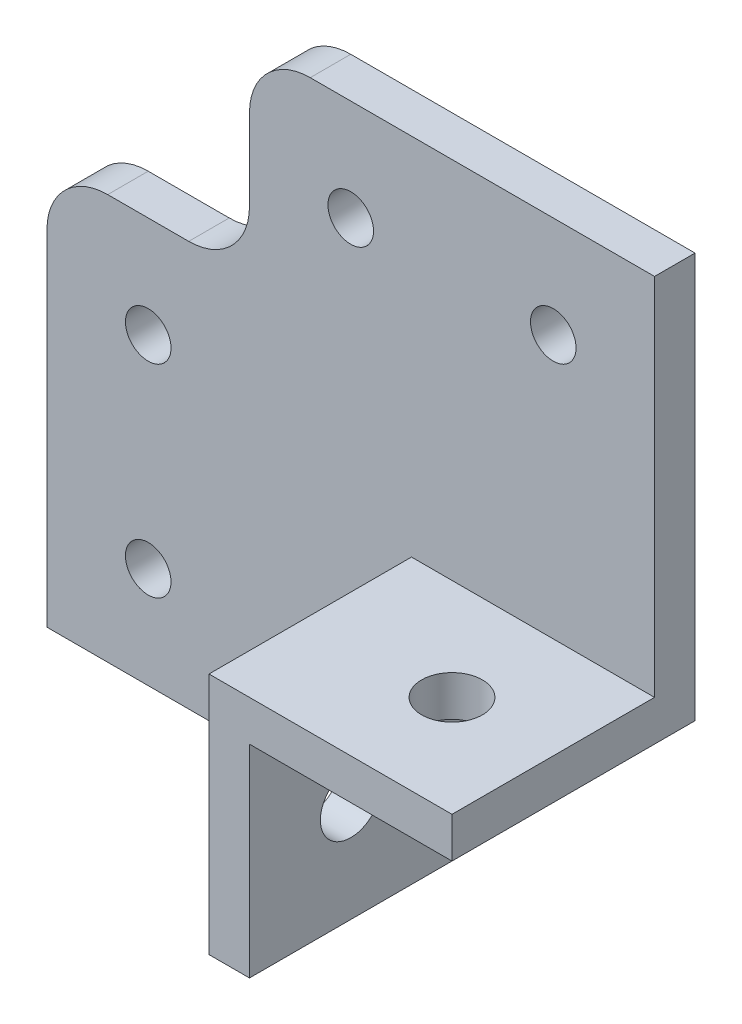
from build123d import *

# Parameters (mm, degrees)
BOSS_EXTRU_1_DEPTH      = 4
BOSS_EXTRU_2_DEPTH      = 20
ESQUISSE3_R             = 3
ENL_V_MAT_EXTRU_1_DEPTH = 25
ESQUISSE4_R             = 3
ENL_V_MAT_EXTRU_2_DEPTH = 25
ESQUISSE5_R             = 2.25
ENL_V_MAT_EXTRU_3_DEPTH = 5
CONG_1_R                = 6


with BuildPart() as part:
    # Esquisse1 → Boss.-Extru.1 (new body)
    with BuildSketch(Plane.XY):
        Polygon((-20, 60), (-20, 40), (-40, 40), (-40, 0), (0, 0), (0, 20), (20, 20), (20, 60), align=None)
    extrude(amount=BOSS_EXTRU_1_DEPTH)

    # Esquisse2 → Boss.-Extru.2 (add)
    with BuildSketch(Plane.XY.offset(4)):
        Polygon((20, 20), (20, 24), (-4, 24), (-4, 0), (0, 0), (0, 20), align=None)
    extrude(amount=BOSS_EXTRU_2_DEPTH)

    # Esquisse3 → Enlèv. mat.-Extru.1 (cut, through all)
    with BuildSketch(Plane.ZY.offset(4)):
        with Locations(Location((14, 10, 0), (0, 0, 270))):  # turned: the seam where the file's is
            Circle(ESQUISSE3_R)
    extrude(amount=-ENL_V_MAT_EXTRU_1_DEPTH, mode=Mode.SUBTRACT)

    # Esquisse4 → Enlèv. mat.-Extru.2 (cut, through all)
    with BuildSketch(Plane(origin=(0, 24, 0), x_dir=(1, 0, 0), z_dir=(0, 1, 0))):
        with Locations(Location((10, -14, 0), (0, 0, 180))):  # turned: the seam where the file's is
            Circle(ESQUISSE4_R)
    extrude(amount=-ENL_V_MAT_EXTRU_2_DEPTH, mode=Mode.SUBTRACT)

    # Esquisse5 → Enlèv. mat.-Extru.3 (cut, through all)
    with BuildSketch(Plane.XY.offset(4)):
        with Locations((10, 50)):
            Circle(ESQUISSE5_R)
        with Locations((-10, 50)):
            Circle(ESQUISSE5_R)
        with Locations((-30, 30)):
            Circle(ESQUISSE5_R)
        with Locations((-30, 10)):
            Circle(ESQUISSE5_R)
    extrude(amount=-ENL_V_MAT_EXTRU_3_DEPTH, mode=Mode.SUBTRACT)

    # Congé1
    cong_1_edges = [part.edges().sort_by_distance(p)[0] for p in [
        (-40, 40, 2),
        (-20, 40, 2),
        (-20, 60, 2),
    ]]
    fillet(cong_1_edges, radius=CONG_1_R)


solid = part.part
